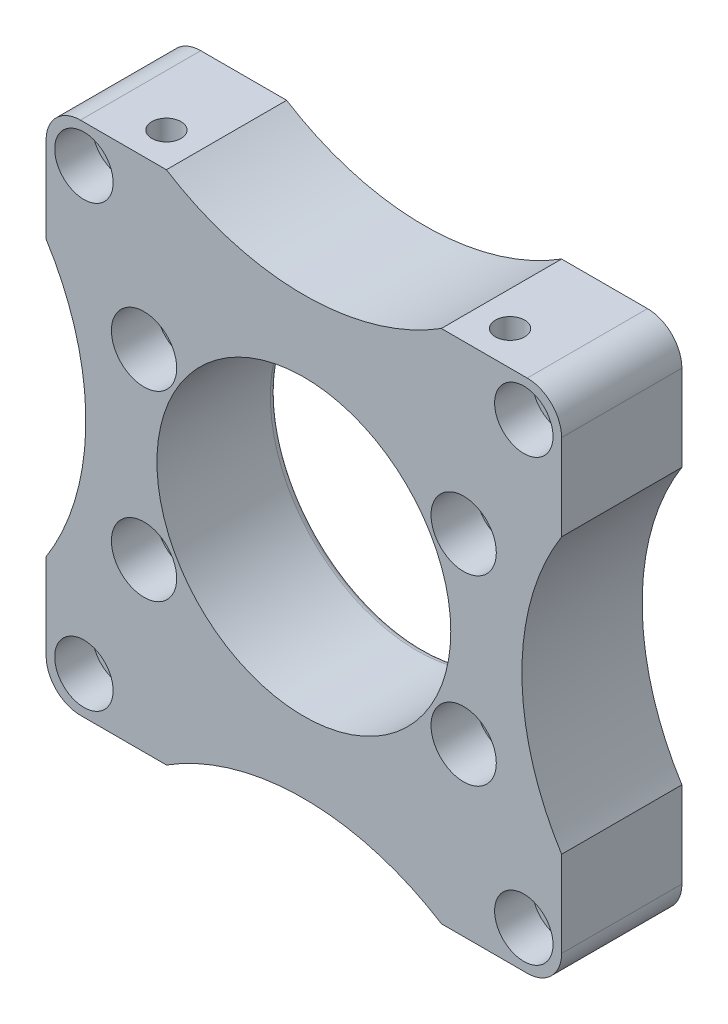
from build123d import *

# Parameters (mm, degrees)
ESQUISSE2_W                   = 150
ESQUISSE2_H                   = 150
BOSS_EXTRU_1_DEPTH            = 35
ESQUISSE3_R                   = 42.75
ENL_V_MAT_EXTRU_2_DEPTH       = 40
ESQUISSE5_R                   = 6
ENL_V_MAT_EXTRU_3_DEPTH       = 40
ESQUISSE6_R                   = 9.5
ENL_V_MAT_EXTRU_4_DEPTH       = 13
ESQUISSE7_R                   = 5.25
ENL_V_MAT_EXTRU_5_DEPTH       = 40
ESQUISSE8_R                   = 8.5
ENL_V_MAT_EXTRU_6_DEPTH       = 11
ESQUISSE9_R                   = 4.25
ENL_V_MAT_EXTRU_7_DEPTH       = 25
ENL_V_MAT_EXTRU_8_DEPTH       = 1
ENL_V_MAT_EXTRU_8_DEPTH_BACK  = 36
ENL_V_MAT_EXTRU_12_DEPTH      = 1
ENL_V_MAT_EXTRU_12_DEPTH_BACK = 36
ENL_V_MAT_EXTRU_13_DEPTH      = 1
ENL_V_MAT_EXTRU_13_DEPTH_BACK = 36
ENL_V_MAT_EXTRU_14_DEPTH      = 1
ENL_V_MAT_EXTRU_14_DEPTH_BACK = 36
CONG_1_R                      = 10
CONG_2_R                      = 10
CONG_3_R                      = 10
CONG_4_R                      = 10
CONG_5_R                      = 2


with BuildPart() as part:
    # Esquisse2 → Boss.-Extru.1 (new body)
    with BuildSketch(Plane.XY):
        with Locations((-75, 75)):
            Rectangle(ESQUISSE2_W, ESQUISSE2_H)
    extrude(amount=BOSS_EXTRU_1_DEPTH)

    # Esquisse3 → Enlèv. mat.-Extru.2 (cut)
    with BuildSketch(Plane.XY.offset(35)):
        with Locations((-75, 75)):
            Circle(ESQUISSE3_R)
    extrude(amount=-ENL_V_MAT_EXTRU_2_DEPTH, mode=Mode.SUBTRACT)

    # Esquisse5 → Enlèv. mat.-Extru.3 (cut)
    with BuildSketch(Plane.XY.offset(35)):
        with Locations((-28.5, 101.5)):
            Circle(ESQUISSE5_R)
        with Locations((-28.5, 48.5)):
            Circle(ESQUISSE5_R)
        with Locations((-121.5, 48.5)):
            Circle(ESQUISSE5_R)
        with Locations((-121.5, 101.5)):
            Circle(ESQUISSE5_R)
    extrude(amount=-ENL_V_MAT_EXTRU_3_DEPTH, mode=Mode.SUBTRACT)

    # Esquisse6 → Enlèv. mat.-Extru.4 (cut)
    with BuildSketch(Plane.XY.offset(35)):
        with Locations((-28.5, 101.5)):
            Circle(ESQUISSE6_R)
        with Locations((-28.5, 48.5)):
            Circle(ESQUISSE6_R)
        with Locations((-121.5, 48.5)):
            Circle(ESQUISSE6_R)
        with Locations((-121.5, 101.5)):
            Circle(ESQUISSE6_R)
    extrude(amount=-ENL_V_MAT_EXTRU_4_DEPTH, mode=Mode.SUBTRACT)

    # Esquisse7 → Enlèv. mat.-Extru.5 (cut)
    with BuildSketch(Plane.XY.offset(35)):
        with Locations((-11, 139)):
            Circle(ESQUISSE7_R)
        with Locations((-11, 11)):
            Circle(ESQUISSE7_R)
        with Locations((-139, 11)):
            Circle(ESQUISSE7_R)
        with Locations((-139, 139)):
            Circle(ESQUISSE7_R)
    extrude(amount=-ENL_V_MAT_EXTRU_5_DEPTH, mode=Mode.SUBTRACT)

    # Esquisse8 → Enlèv. mat.-Extru.6 (cut)
    with BuildSketch(Plane.XY.offset(35)):
        with Locations((-11, 139)):
            Circle(ESQUISSE8_R)
        with Locations((-11, 11)):
            Circle(ESQUISSE8_R)
        with Locations((-139, 11)):
            Circle(ESQUISSE8_R)
        with Locations((-139, 139)):
            Circle(ESQUISSE8_R)
    extrude(amount=-ENL_V_MAT_EXTRU_6_DEPTH, mode=Mode.SUBTRACT)

    # Esquisse9 → Enlèv. mat.-Extru.7 (cut)
    with BuildSketch(Plane(origin=(0, 150, 0), x_dir=(1, 0, 0), z_dir=(0, 1, 0))):
        with Locations(Location((-25, -25, 0), (0, 0, 270))):  # turned: the seam where the file's is
            Circle(ESQUISSE9_R)
        with Locations(Location((-125, -25, 0), (0, 0, 270))):  # turned: the seam where the file's is
            Circle(ESQUISSE9_R)
    extrude(amount=-ENL_V_MAT_EXTRU_7_DEPTH, mode=Mode.SUBTRACT)

    # Esquisse19 → Enlèv. mat.-Extru.8 (cut, two sides)
    with BuildSketch(Plane.XY.offset(35)) as enl_v_mat_extru_8_sk:
        with BuildLine():
            Line((206.944620495, 443.229107967), (0, 115))
            ThreePointArc((0, 115), (-11.557112298, 75), (0, 35))
            Line((0, 35), (206.944620495, -293.229107967))
            Line((206.944620495, -293.229107967), (982.986947353, -293.229107967))
            Line((982.986947353, -293.229107967), (982.986947353, 443.229107967))
            Line((982.986947353, 443.229107967), (206.944620495, 443.229107967))
        make_face()
    extrude(amount=ENL_V_MAT_EXTRU_8_DEPTH, mode=Mode.SUBTRACT)
    extrude(enl_v_mat_extru_8_sk.sketch, amount=-ENL_V_MAT_EXTRU_8_DEPTH_BACK, mode=Mode.SUBTRACT)

    # Esquisse22 → Enlèv. mat.-Extru.12 (cut, two sides)
    with BuildSketch(Plane.XY.offset(35)) as enl_v_mat_extru_12_sk:
        with BuildLine():
            Line((-443.229107967, -206.944620495), (-115, 0))
            ThreePointArc((-115, 0), (-75, 11.557112298), (-35, 0))
            Line((-35, 0), (293.229107967, -206.944620495))
            Line((293.229107967, -206.944620495), (293.229107967, -982.986947353))
            Line((293.229107967, -982.986947353), (-443.229107967, -982.986947353))
            Line((-443.229107967, -982.986947353), (-443.229107967, -206.944620495))
        make_face()
    extrude(amount=ENL_V_MAT_EXTRU_12_DEPTH, mode=Mode.SUBTRACT)
    extrude(enl_v_mat_extru_12_sk.sketch, amount=-ENL_V_MAT_EXTRU_12_DEPTH_BACK, mode=Mode.SUBTRACT)

    # Esquisse27 → Enlèv. mat.-Extru.13 (cut, two sides)
    with BuildSketch(Plane.XY.offset(35)) as enl_v_mat_extru_13_sk:
        with BuildLine():
            Line((-356.944620495, 443.229107967), (-150, 115))
            ThreePointArc((-150, 115), (-138.442887702, 75), (-150, 35))
            Line((-150, 35), (-356.944620495, -293.229107967))
            Line((-356.944620495, -293.229107967), (-1132.986947353, -293.229107967))
            Line((-1132.986947353, -293.229107967), (-1132.986947353, 443.229107967))
            Line((-1132.986947353, 443.229107967), (-356.944620495, 443.229107967))
        make_face()
    extrude(amount=ENL_V_MAT_EXTRU_13_DEPTH, mode=Mode.SUBTRACT)
    extrude(enl_v_mat_extru_13_sk.sketch, amount=-ENL_V_MAT_EXTRU_13_DEPTH_BACK, mode=Mode.SUBTRACT)

    # Esquisse28 → Enlèv. mat.-Extru.14 (cut, two sides)
    with BuildSketch(Plane.XY.offset(35)) as enl_v_mat_extru_14_sk:
        with BuildLine():
            Line((-443.229107967, 356.944620495), (-115, 150))
            ThreePointArc((-115, 150), (-75, 138.442887702), (-35, 150))
            Line((-35, 150), (293.229107967, 356.944620495))
            Line((293.229107967, 356.944620495), (293.229107967, 1132.986947353))
            Line((293.229107967, 1132.986947353), (-443.229107967, 1132.986947353))
            Line((-443.229107967, 1132.986947353), (-443.229107967, 356.944620495))
        make_face()
    extrude(amount=ENL_V_MAT_EXTRU_14_DEPTH, mode=Mode.SUBTRACT)
    extrude(enl_v_mat_extru_14_sk.sketch, amount=-ENL_V_MAT_EXTRU_14_DEPTH_BACK, mode=Mode.SUBTRACT)

    # Congé1
    cong_1_edges = [part.edges().sort_by_distance(p)[0] for p in [
        (0, 150, 17.5),
    ]]
    fillet(cong_1_edges, radius=CONG_1_R)

    # Congé2
    cong_2_edges = [part.edges().sort_by_distance(p)[0] for p in [
        (-150, 150, 17.5),
    ]]
    fillet(cong_2_edges, radius=CONG_2_R)

    # Congé3
    cong_3_edges = [part.edges().sort_by_distance(p)[0] for p in [
        (-150, 0, 17.5),
    ]]
    fillet(cong_3_edges, radius=CONG_3_R)

    # Congé4
    cong_4_edges = [part.edges().sort_by_distance(p)[0] for p in [
        (0, 0, 17.5),
    ]]
    fillet(cong_4_edges, radius=CONG_4_R)

    # Congé5
    cong_5_edges = [part.edges().sort_by_distance(p)[0] for p in [
        (-117.75, 75, 0),
    ]]
    fillet(cong_5_edges, radius=CONG_5_R)


solid = part.part
